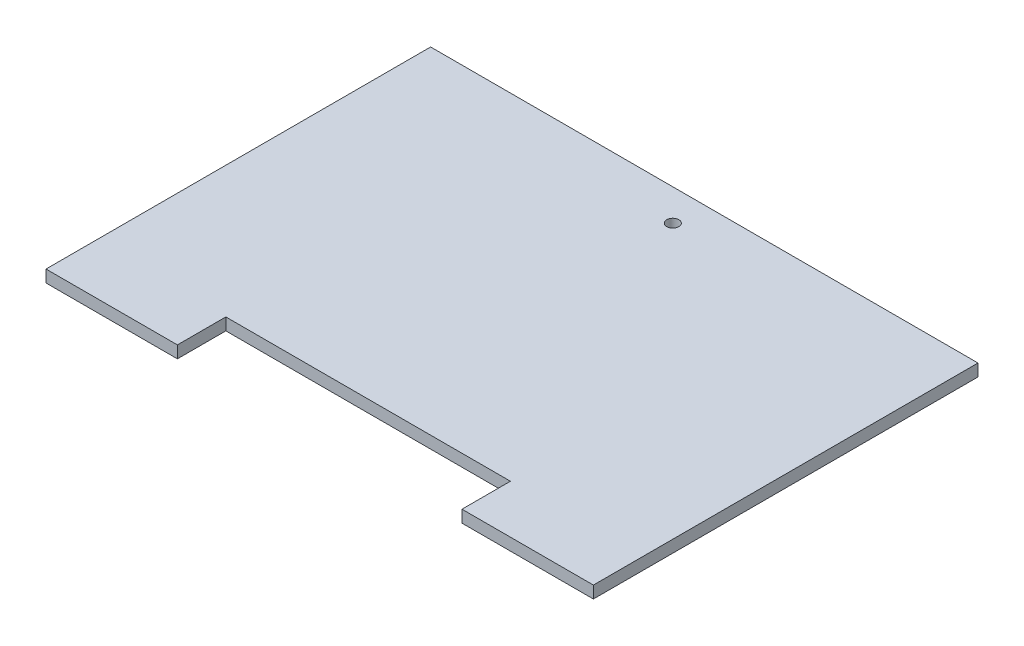
from build123d import *

# Parameters (mm, degrees)
SKETCH1_W               = 287.02
SKETCH1_H               = 201.676
BOSS_EXTRUDE1_DEPTH     = 3.175
SKETCH2_W               = 149.225
SKETCH2_H               = 25.4
CUT_EXTRUDE1_DEPTH      = 1
CUT_EXTRUDE1_DEPTH_BACK = 7.35
SKETCH3_R               = 3.175
CUT_EXTRUDE2_DEPTH      = 1
CUT_EXTRUDE2_DEPTH_BACK = 7.35


with BuildPart() as part:
    # Sketch1 → Boss-Extrude1 (new body, symmetric)
    with BuildSketch(Plane(origin=(0, 0, 0), x_dir=(1, 0, 0), z_dir=(0, 1, 0))):
        Rectangle(SKETCH1_W, SKETCH1_H)
    extrude(amount=BOSS_EXTRUDE1_DEPTH, both=True)

    # Sketch2 → Cut-Extrude1 (cut, two sides)
    with BuildSketch(Plane(origin=(0, 3.175, 0), x_dir=(1, 0, 0), z_dir=(0, 1, 0))) as cut_extrude1_sk:
        with Locations((0, -88.138)):
            Rectangle(SKETCH2_W, SKETCH2_H)
    extrude(amount=CUT_EXTRUDE1_DEPTH, mode=Mode.SUBTRACT)
    extrude(cut_extrude1_sk.sketch, amount=-CUT_EXTRUDE1_DEPTH_BACK, mode=Mode.SUBTRACT)

    # Sketch3 → Cut-Extrude2 (cut, two sides)
    with BuildSketch(Plane.XZ.offset(3.175)) as cut_extrude2_sk:
        with Locations((41.91, 88.138)):
            Circle(SKETCH3_R)
        with Locations((0, -84.328)):
            Circle(SKETCH3_R)
        with Locations((-41.91, 88.138)):
            Circle(SKETCH3_R)
    extrude(amount=CUT_EXTRUDE2_DEPTH, mode=Mode.SUBTRACT)
    extrude(cut_extrude2_sk.sketch, amount=-CUT_EXTRUDE2_DEPTH_BACK, mode=Mode.SUBTRACT)


solid = part.part
